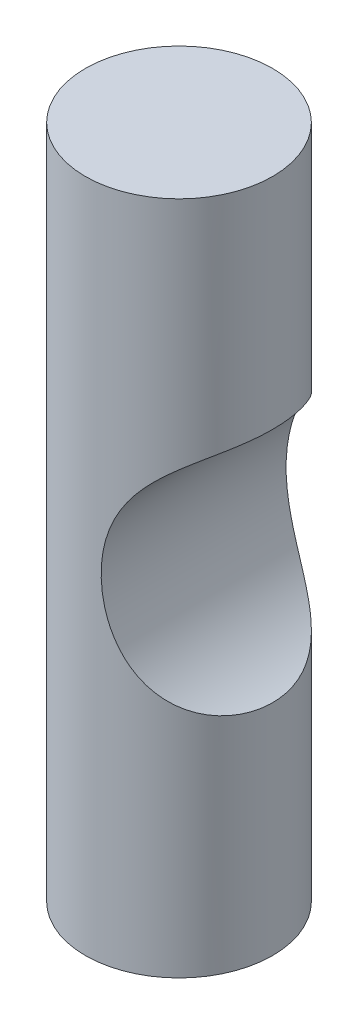
from build123d import *

# Parameters (mm, degrees)
SKETCH1_R               = 4
BOSS_EXTRUDE1_DEPTH     = 28.83
SKETCH2_R               = 5.475
CUT_EXTRUDE1_DEPTH      = 5
CUT_EXTRUDE1_DEPTH_BACK = 5
SKETCH3_R               = 2.5
BOSS_EXTRUDE2_DEPTH     = 1


with BuildPart() as part:
    # Sketch1 → Boss-Extrude1 (new body)
    with BuildSketch(Plane(origin=(0, 0, 0), x_dir=(1, 0, 0), z_dir=(0, 1, 0))):
        Circle(SKETCH1_R)
    extrude(amount=BOSS_EXTRUDE1_DEPTH)

    # Sketch2 → Cut-Extrude1 (cut, two sides)
    with BuildSketch(Plane.XY) as cut_extrude1_sk:
        with Locations((6.1, 14.415)):
            Circle(SKETCH2_R)
    extrude(amount=CUT_EXTRUDE1_DEPTH, mode=Mode.SUBTRACT)
    extrude(cut_extrude1_sk.sketch, amount=-CUT_EXTRUDE1_DEPTH_BACK, mode=Mode.SUBTRACT)

    # Sketch3 → Boss-Extrude2 (add)
    with BuildSketch(Plane.XZ):
        with Locations((0, 0.069764056)):
            Circle(SKETCH3_R)
    extrude(amount=BOSS_EXTRUDE2_DEPTH)


solid = part.part
